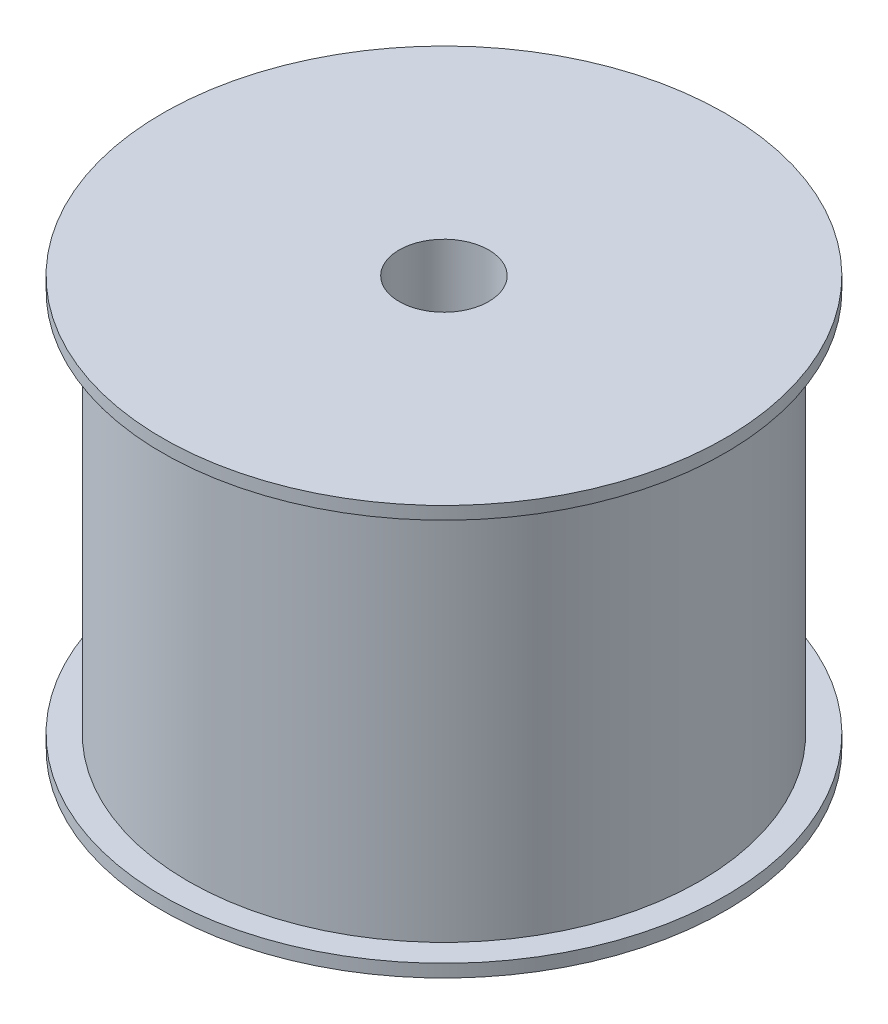
from build123d import *


with BuildPart() as part:
    # Sketch2 → Revolve1 (revolve)
    with BuildSketch(Plane.XY):
        Polygon((1.75, 9.020833333), (11, 9.020833333), (11, 8.520833333), (10, 8.520833333), (10, -6.479166667), (11, -6.479166667), (11, -6.979166667), (2.75, -6.979166667), (2.75, 6.520833333), (1.75, 6.520833333), align=None)
    revolve(axis=Axis((0, 0, 0), (0, 1, 0)))


solid = part.part
